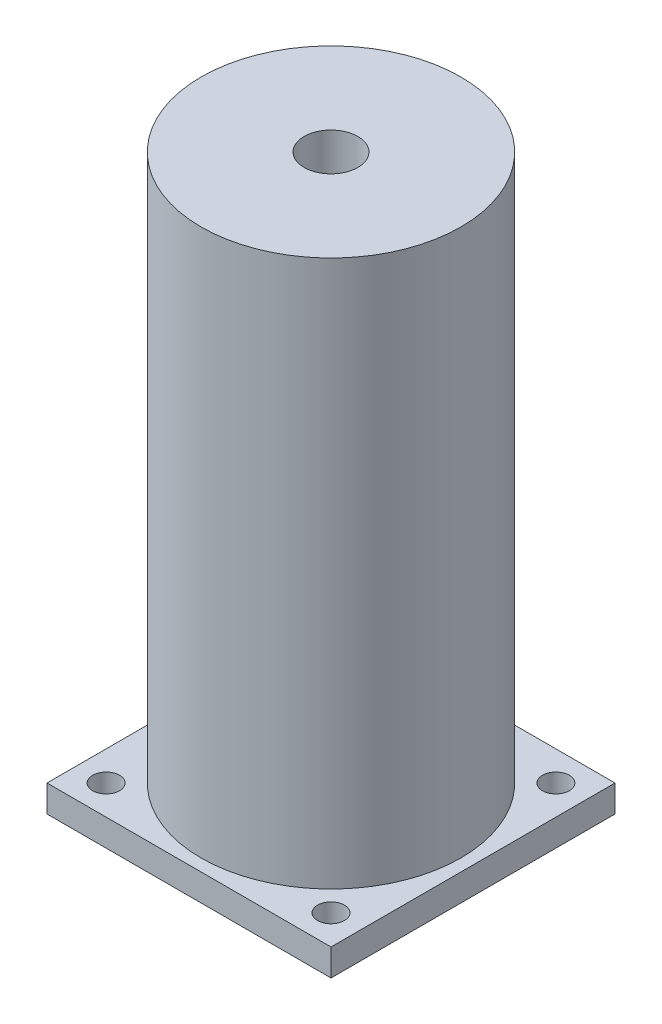
from build123d import *

# Parameters (mm, degrees)
SKETCH1_W             = 31.7
SKETCH1_H             = 31.7
BOSS_EXTRUDE1_DEPTH   = 3
SKETCH2_R             = 14.5
BOSS_EXTRUDE2_DEPTH   = 61
F_3_0MM_DOWEL_HOLE1_D = 3
SKETCH6_R             = 3
CUT_EXTRUDE1_DEPTH    = 68.81183525


with BuildPart() as part:
    # Sketch1 → Boss-Extrude1 (new body)
    with BuildSketch(Plane(origin=(0, 0, 0), x_dir=(1, 0, 0), z_dir=(0, 1, 0))):
        Rectangle(SKETCH1_W, SKETCH1_H)
    extrude(amount=BOSS_EXTRUDE1_DEPTH)

    # Sketch2 → Boss-Extrude2 (add)
    with BuildSketch(Plane(origin=(0, 3, 0), x_dir=(1, 0, 0), z_dir=(0, 1, 0))):
        Circle(SKETCH2_R)
    extrude(amount=BOSS_EXTRUDE2_DEPTH)

    # Ø3.0mm Dowel Hole1 (through all)
    with Locations(Plane(origin=(0, 0, 0), x_dir=(-1, 0, 0), z_dir=(0, -1, 0))):
        with Locations((12.551145366, -12.551145366), (-12.551145366, -12.551145366), (12.551145366, 12.551145366), (-12.551145366, 12.551145366)):
            Hole(F_3_0MM_DOWEL_HOLE1_D / 2)

    # Sketch6 → Cut-Extrude1 (cut, through all)
    with BuildSketch(Plane(origin=(0, 64, 0), x_dir=(1, 0, 0), z_dir=(0, 1, 0))):
        Circle(SKETCH6_R)
    extrude(amount=-CUT_EXTRUDE1_DEPTH, mode=Mode.SUBTRACT)


solid = part.part
